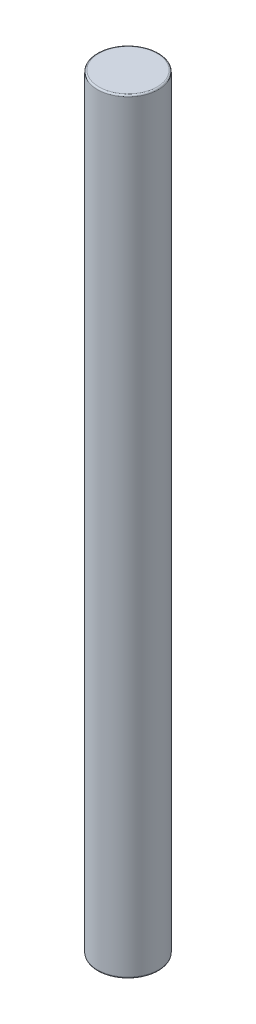
from build123d import *

# Parameters (mm, degrees)
SKETCH1_R           = 4
BOSS_EXTRUDE1_DEPTH = 100
FILLET1_R           = 0.2


with BuildPart() as part:
    # Sketch1 → Boss-Extrude1 (new body)
    with BuildSketch(Plane(origin=(0, 0, 0), x_dir=(1, 0, 0), z_dir=(0, 1, 0))):
        Circle(SKETCH1_R)
    extrude(amount=BOSS_EXTRUDE1_DEPTH)

    # Fillet1
    fillet1_edges = [part.edges().sort_by_distance(p)[0] for p in [
        (-4, 0, 0),
        (-4, 100, 0),
    ]]
    fillet(fillet1_edges, radius=FILLET1_R)


solid = part.part
